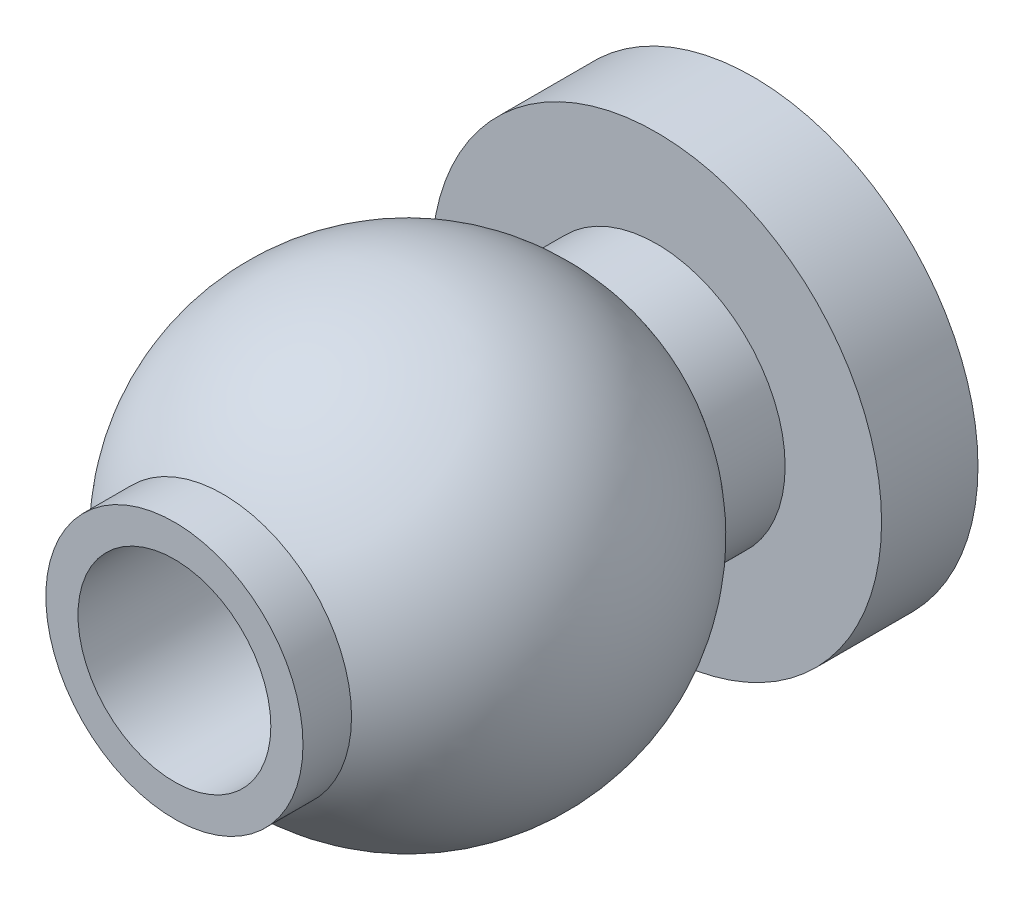
from build123d import *


with BuildPart() as part:
    # Sketch1 → Revolve1 (revolve)
    with BuildSketch(Plane(origin=(0, 0, 0), x_dir=(0, 0, -1), z_dir=(1, 0, 0))):
        with BuildLine():
            Line((0, 1.5), (9, 1.5))
            Line((9, 1.5), (9, 3.5))
            Line((9, 3.5), (7.5, 3.5))
            Line((7.5, 3.5), (7.5, 2))
            Line((7.5, 2), (6.5, 2))
            ThreePointArc((6.5, 2), (3.627718677, 3.5), (0.755437353, 2))
            Line((0.755437353, 2), (0, 2))
            Line((0, 2), (0, 1.5))
        make_face()
    revolve(axis=Axis((0, 0, 0), (0, 0, -1)))


solid = part.part
